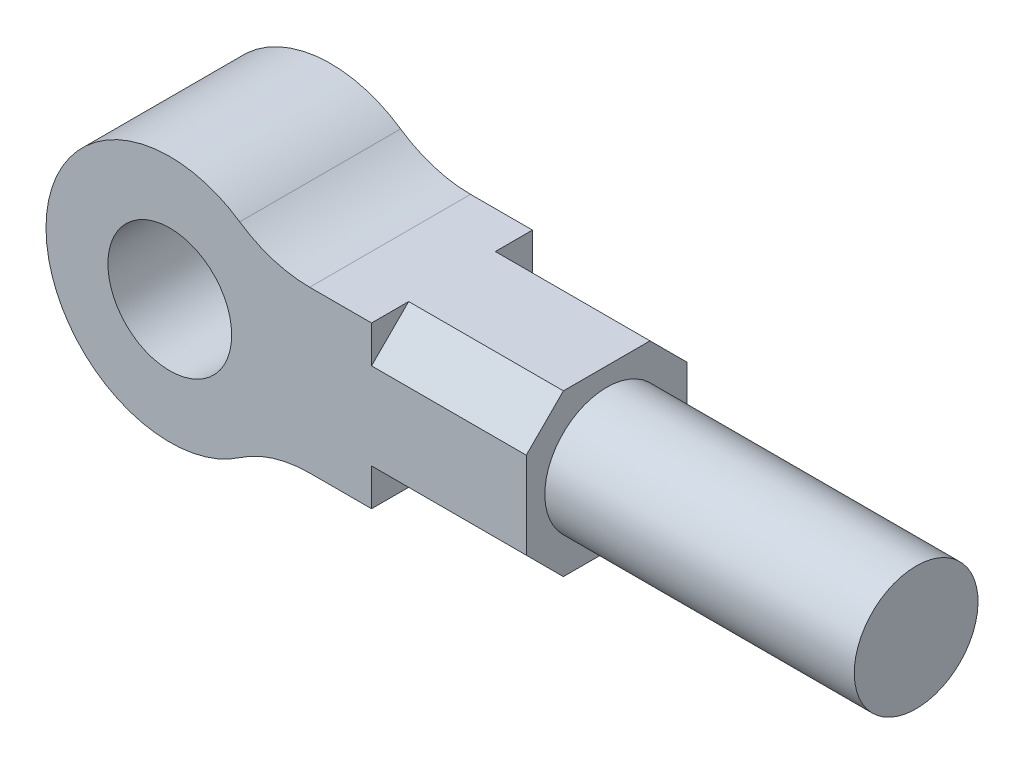
from build123d import *

# Parameters (mm, degrees)
SKETCH1_R           = 10
BOSS_EXTRUDE1_DEPTH = 13
CUT_EXTRUDE1_DEPTH  = 25
SKETCH3_3_R         = 10
BOSS_EXTRUDE2_DEPTH = 50


with BuildPart() as part:
    # Sketch1 → Boss-Extrude1 (new, symmetric)
    with BuildSketch(Plane.XY):
        with BuildLine():
            Line((57.605309111, 13), (57.605309111, -13))
            Line((57.605309111, -13), (22.605309111, -13))
            ThreePointArc((22.605309111, -13), (16.689229328, -13.895026825), (11.302654555, -16.5))
            ThreePointArc((11.302654555, -16.5), (-20, 0), (11.302654555, 16.5))
            ThreePointArc((11.302654555, 16.5), (16.689229328, 13.895026825), (22.605309111, 13))
            Line((22.605309111, 13), (57.605309111, 13))
        make_face()
        Circle(SKETCH1_R, mode=Mode.SUBTRACT)
    extrude(amount=BOSS_EXTRUDE1_DEPTH, both=True)

    # Sketch3 → Cut-Extrude1 (cut)
    with BuildSketch(Plane(origin=(57.605309111, 0, 0), x_dir=(0, 0, -1), z_dir=(1, 0, 0))):
        Polygon((13, 7), (13, 13), (7, 13), align=None)
        Polygon((13, -13), (13, -7), (7, -13), align=None)
        Polygon((-13, 7), (-7, 13), (-13, 13), align=None)
        Polygon((-13, -13), (-7, -13), (-13, -7), align=None)
    extrude(amount=-CUT_EXTRUDE1_DEPTH, mode=Mode.SUBTRACT)

    # Sketch3_3 → Boss-Extrude2 (add)
    with BuildSketch(Plane(origin=(57.605309111, 0, 0), x_dir=(0, 0, -1), z_dir=(1, 0, 0))):
        Circle(SKETCH3_3_R)
    extrude(amount=BOSS_EXTRUDE2_DEPTH)


solid = part.part
